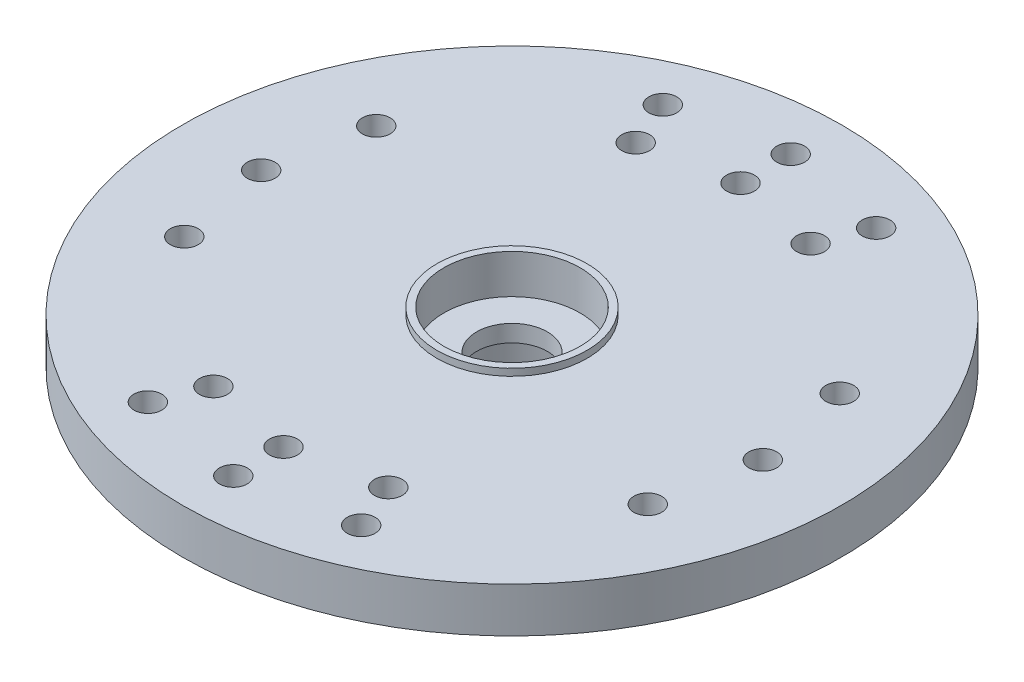
from build123d import *

# Parameters (mm, degrees)
SKETCH18_R                      = 11.825
EXTRUDE17_DEPTH                 = 1.6129
SKETCH19_R                      = 3.4
EXTRUDE19_DEPTH                 = 4.1
SKETCH20_R                      = 0.5
SKETCH20_R_2                    = 1.27
EXTRUDE20_DEPTH                 = 5.1
SKETCH23_R                      = 0.5
CUT_EXTRUDE1_DEPTH              = 5.1
CIRPATTERN1_COUNT               = 2
CIRPATTERN1_ANGLE               = 22.5
CIRPATTERN1_THE_OTHER_WAY_COUNT = 2
CIRPATTERN1_THE_OTHER_WAY_ANGLE = 22.5
MIRROR2_COPY_1_SKETCH_R         = 0.5
MIRROR2_COPY_1_DEPTH            = 5.1
MIRROR2_COPY_2_SKETCH_R         = 0.5
MIRROR2_COPY_2_DEPTH            = 5.1
SKETCH21_R                      = 2.44475
EXTRUDE21_DEPTH                 = 1.1557
SKETCH22_R                      = 2.286
EXTRUDE22_DEPTH                 = 2.3368
EXTRUDE22_TAPER                 = 5
SKETCH24_R                      = 2.69475
SKETCH24_R_2                    = 2.44475
BOSS_EXTRUDE1_DEPTH             = 0.25
FILLET1_R                       = 0.5


with BuildPart() as part:
    # Sketch18 → Extrude17 (new body)
    with BuildSketch(Plane(origin=(0, 0, 0), x_dir=(1, 0, 0), z_dir=(0, 1, 0))):
        Circle(SKETCH18_R)
    extrude(amount=EXTRUDE17_DEPTH)

    # Sketch19 → Extrude19 (add)
    with BuildSketch(Plane(origin=(0, 1.6129, 0), x_dir=(1, 0, 0), z_dir=(0, 1, 0))):
        Circle(SKETCH19_R)
    extrude(amount=-EXTRUDE19_DEPTH)

    # Sketch20 → Extrude20 (cut, through all)
    with BuildSketch(Plane(origin=(0, 1.6129, 0), x_dir=(1, 0, 0), z_dir=(0, 1, 0))):
        with Locations((-9, 0)):
            Circle(SKETCH20_R)
        Circle(SKETCH20_R_2)
        with Locations((-8.314915793, 3.444150891)):
            Circle(SKETCH20_R)
        with Locations((-8.314915793, -3.444150891)):
            Circle(SKETCH20_R)
    extrude20 = extrude(amount=-EXTRUDE20_DEPTH, mode=Mode.SUBTRACT)

    # Mirror1: Extrude20 across plane
    add(extrude20.mirror(Plane(origin=(0, 0, 0), x_dir=(0, 0, 1), z_dir=(1, 0, 0))), mode=Mode.SUBTRACT)

    # Sketch23 → Cut-Extrude1 (cut, through all)
    with BuildSketch(Plane(origin=(0, 1.6129, 0), x_dir=(1, 0, 0), z_dir=(0, 1, 0))):
        with Locations((0, 8.2)):
            Circle(SKETCH23_R)
        with Locations((0, 10)):
            Circle(SKETCH23_R)
    cut_extrude1 = extrude(amount=-CUT_EXTRUDE1_DEPTH, mode=Mode.SUBTRACT)

    # CirPattern1: Cut-Extrude1 ×2 about axis
    cirpattern1_axis = Axis((0, 0, 0), (0, 1, 0))
    for i in range(1, CIRPATTERN1_COUNT):
        add(cut_extrude1.rotate(cirpattern1_axis, i * CIRPATTERN1_ANGLE / (CIRPATTERN1_COUNT - 1)), mode=Mode.SUBTRACT)

    # CirPattern1 the other way: Cut-Extrude1 ×2 about axis
    cirpattern1_the_other_way_axis = Axis((0, 0, 0), (0, -1, 0))
    for i in range(1, CIRPATTERN1_THE_OTHER_WAY_COUNT):
        add(cut_extrude1.rotate(cirpattern1_the_other_way_axis, i * CIRPATTERN1_THE_OTHER_WAY_ANGLE / (CIRPATTERN1_THE_OTHER_WAY_COUNT - 1)), mode=Mode.SUBTRACT)

    # Mirror2: Cut-Extrude1 across plane
    add(cut_extrude1.mirror(Plane.XY), mode=Mode.SUBTRACT)

    # Mirror2 copy 1 sketch → Mirror2 copy 1 (cut, through all)
    with BuildSketch(Plane(origin=(0, 1.6129, 0), x_dir=(0.923879533, 0, 0.382683432), z_dir=(0, 1, 0))):
        with Locations((0, -8.2)):
            Circle(MIRROR2_COPY_1_SKETCH_R)
        with Locations((0, -10)):
            Circle(MIRROR2_COPY_1_SKETCH_R)
    extrude(amount=-MIRROR2_COPY_1_DEPTH, mode=Mode.SUBTRACT)

    # Mirror2 copy 2 sketch → Mirror2 copy 2 (cut, through all)
    with BuildSketch(Plane(origin=(0, 1.6129, 0), x_dir=(0.923879533, 0, -0.382683432), z_dir=(0, 1, 0))):
        with Locations((0, -8.2)):
            Circle(MIRROR2_COPY_2_SKETCH_R)
        with Locations((0, -10)):
            Circle(MIRROR2_COPY_2_SKETCH_R)
    extrude(amount=-MIRROR2_COPY_2_DEPTH, mode=Mode.SUBTRACT)

    # Sketch21 → Extrude21 (cut)
    with BuildSketch(Plane(origin=(0, 1.6129, 0), x_dir=(1, 0, 0), z_dir=(0, 1, 0))):
        Circle(SKETCH21_R)
    extrude(amount=-EXTRUDE21_DEPTH, mode=Mode.SUBTRACT)

    # Sketch22 → Extrude22 (cut)
    with BuildSketch(Plane.XZ.offset(2.4871)):
        Circle(SKETCH22_R)
    extrude(amount=-EXTRUDE22_DEPTH, taper=EXTRUDE22_TAPER, mode=Mode.SUBTRACT)

    # Sketch24 → Boss-Extrude1 (add)
    with BuildSketch(Plane(origin=(0, 1.6129, 0), x_dir=(1, 0, 0), z_dir=(0, 1, 0))):
        Circle(SKETCH24_R)
        Circle(SKETCH24_R_2, mode=Mode.SUBTRACT)
    extrude(amount=BOSS_EXTRUDE1_DEPTH)

    # Fillet1
    fillet1_edges = [part.edges().sort_by_distance(p)[0] for p in [
        (-3.4, 0, 0),
    ]]
    fillet(fillet1_edges, radius=FILLET1_R)


solid = part.part
